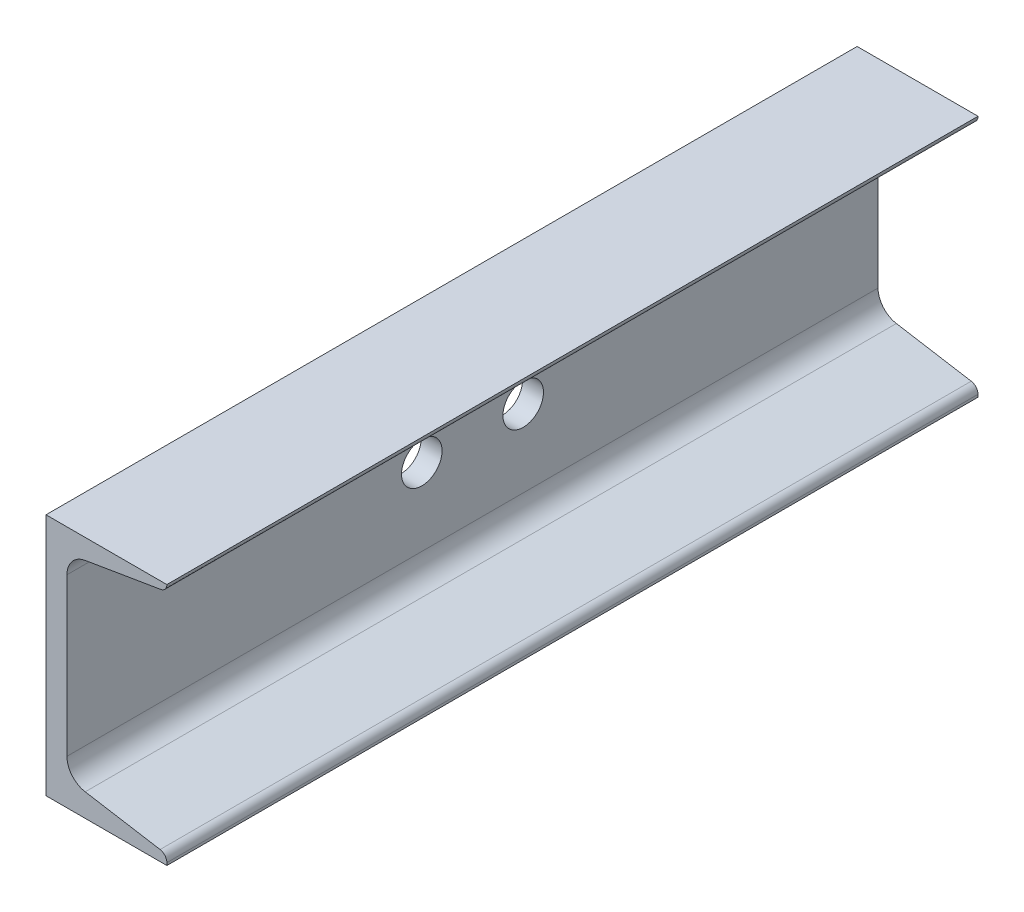
from build123d import *

# Parameters (mm, degrees)
BOSS_EXTRUDE1_DEPTH = 127
CUT_EXTRUDE1_REACH  = 39.846
SKETCH3_R           = 6.35


with BuildPart() as part:
    # Sketch1 → Boss-Extrude1 (new body, symmetric)
    with BuildSketch(Plane.XY):
        with BuildLine():
            Line((37.846, -38.1), (0, -38.1))
            Line((0, -38.1), (0, 38.1))
            Line((0, 38.1), (37.846, 38.1))
            Line((37.846, 38.1), (37.846, 38.095373852))
            Line((37.846, 38.095373852), (37.846, 38.07919906))
            ThreePointArc((37.846, 38.07919906), (37.304749426, 36.602159643), (35.937298827, 35.824550175))
            Line((35.937298827, 35.824550175), (12.279303519, 31.865559515))
            ThreePointArc((12.279303519, 31.865559515), (8.176951722, 29.532731112), (6.5532, 25.101612859))
            Line((6.5532, 25.101612859), (6.5532, -24.125928831))
            ThreePointArc((6.5532, -24.125928831), (8.176951722, -28.557047083), (12.279303519, -30.889875486))
            Line((12.279303519, -30.889875486), (35.725220919, -34.813376476))
            ThreePointArc((35.725220919, -34.813376476), (37.244610473, -35.677386996), (37.846, -37.318541904))
            Line((37.846, -37.318541904), (37.846, -38.1))
        make_face()
    extrude(amount=BOSS_EXTRUDE1_DEPTH, both=True)

    # Sketch3 → Cut-Extrude1 (cut, up to next)
    with BuildSketch(Plane.ZY, mode=Mode.PRIVATE) as cut_extrude1_sk1:
        with Locations((-15.875, 0)):
            Circle(SKETCH3_R)
    cut_extrude1_tool1 = extrude(cut_extrude1_sk1.sketch, amount=-CUT_EXTRUDE1_REACH, mode=Mode.PRIVATE) & part.part
    add(cut_extrude1_tool1.solids().sort_by_distance((0, 0, -15.875))[0], mode=Mode.SUBTRACT)
    # Sketch3 → Cut-Extrude1 (cut, up to next)
    with BuildSketch(Plane.ZY, mode=Mode.PRIVATE) as cut_extrude1_sk2:
        with Locations((15.875, 0)):
            Circle(SKETCH3_R)
    cut_extrude1_tool2 = extrude(cut_extrude1_sk2.sketch, amount=-CUT_EXTRUDE1_REACH, mode=Mode.PRIVATE) & part.part
    add(cut_extrude1_tool2.solids().sort_by_distance((0, 0, 15.875))[0], mode=Mode.SUBTRACT)


solid = part.part
